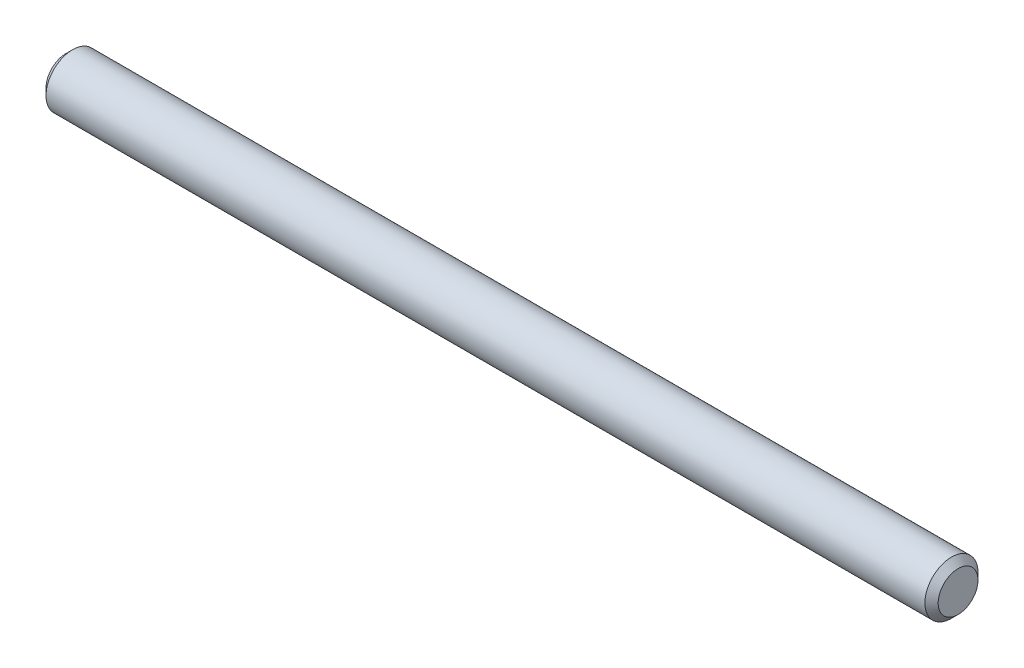
from build123d import *

# Parameters (mm, degrees)
SKETCH2_R           = 4.7625
BOSS_EXTRUDE1_DEPTH = 160
CHAMFER1_SIZE       = 1.190625


with BuildPart() as part:
    # Sketch2 → Boss-Extrude1 (new body)
    with BuildSketch(Plane(origin=(0, 0, 0), x_dir=(0, 0, -1), z_dir=(1, 0, 0))):
        Circle(SKETCH2_R)
    extrude(amount=-BOSS_EXTRUDE1_DEPTH)

    # Chamfer1
    chamfer1_edges = [part.edges().sort_by_distance(p)[0] for p in [
        (-160, 0, 4.7625),
        (0, 0, 4.7625),
    ]]
    chamfer(chamfer1_edges, length=CHAMFER1_SIZE)


solid = part.part
